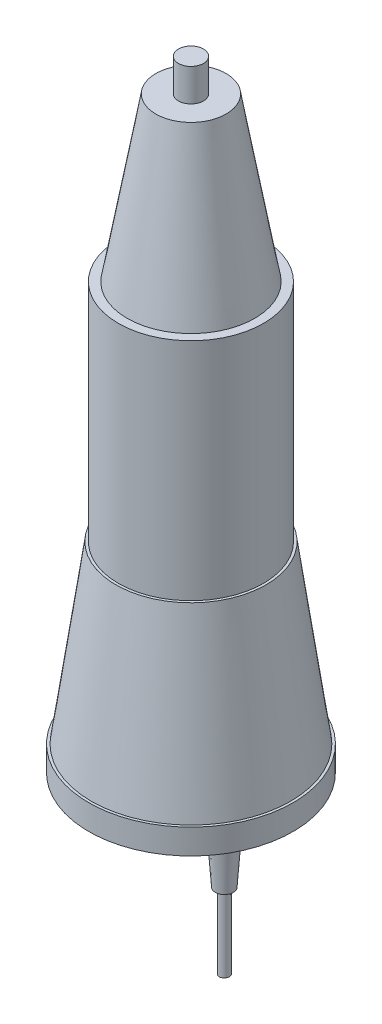
from build123d import *

# Parameters (mm, degrees)
SKETCH1_R           = 29
BOSS_EXTRUDE1_DEPTH = 90
SKETCH2_R           = 25.5
BOSS_EXTRUDE3_DEPTH = 65
BOSS_EXTRUDE3_TAPER = 10
SKETCH4_R           = 5
BOSS_EXTRUDE4_DEPTH = 13
SKETCH10_R          = 30
BOSS_EXTRUDE5_DEPTH = 70
BOSS_EXTRUDE5_TAPER = -8
SKETCH11_R          = 40.837858429
BOSS_EXTRUDE6_DEPTH = 10
SKETCH12_R          = 5
BOSS_EXTRUDE7_DEPTH = 20
BOSS_EXTRUDE7_TAPER = 4
SKETCH14_R          = 2
BOSS_EXTRUDE8_DEPTH = 30


with BuildPart() as part:
    # Sketch1 → Boss-Extrude1 (new body)
    with BuildSketch(Plane(origin=(0, 0, 0), x_dir=(1, 0, 0), z_dir=(0, 1, 0))):
        Circle(SKETCH1_R)
    extrude(amount=BOSS_EXTRUDE1_DEPTH)

    # Sketch2 → Boss-Extrude3 (add)
    with BuildSketch(Plane(origin=(0, 90, 0), x_dir=(1, 0, 0), z_dir=(0, 1, 0))):
        Circle(SKETCH2_R)
    extrude(amount=BOSS_EXTRUDE3_DEPTH, taper=BOSS_EXTRUDE3_TAPER)

    # Sketch4 → Boss-Extrude4 (add)
    with BuildSketch(Plane(origin=(0, 155, 0), x_dir=(1, 0, 0), z_dir=(0, 1, 0))):
        Circle(SKETCH4_R)
    extrude(amount=BOSS_EXTRUDE4_DEPTH)

    # Sketch10 → Boss-Extrude5 (add)
    with BuildSketch(Plane.XZ):
        Circle(SKETCH10_R)
    extrude(amount=BOSS_EXTRUDE5_DEPTH, taper=BOSS_EXTRUDE5_TAPER)

    # Sketch11 → Boss-Extrude6 (add)
    with BuildSketch(Plane.XZ.offset(70)):
        Circle(SKETCH11_R)
    extrude(amount=BOSS_EXTRUDE6_DEPTH)

    # Sketch12 → Boss-Extrude7 (add)
    with BuildSketch(Plane.XZ.offset(80)):
        with Locations((26.346299314, 13.003540379)):
            Circle(SKETCH12_R)
    extrude(amount=BOSS_EXTRUDE7_DEPTH, taper=BOSS_EXTRUDE7_TAPER)

    # Sketch14 → Boss-Extrude8 (add)
    with BuildSketch(Plane.XZ.offset(100)):
        with Locations((26.346299314, 13.003540379)):
            Circle(SKETCH14_R)
    extrude(amount=BOSS_EXTRUDE8_DEPTH)


solid = part.part
